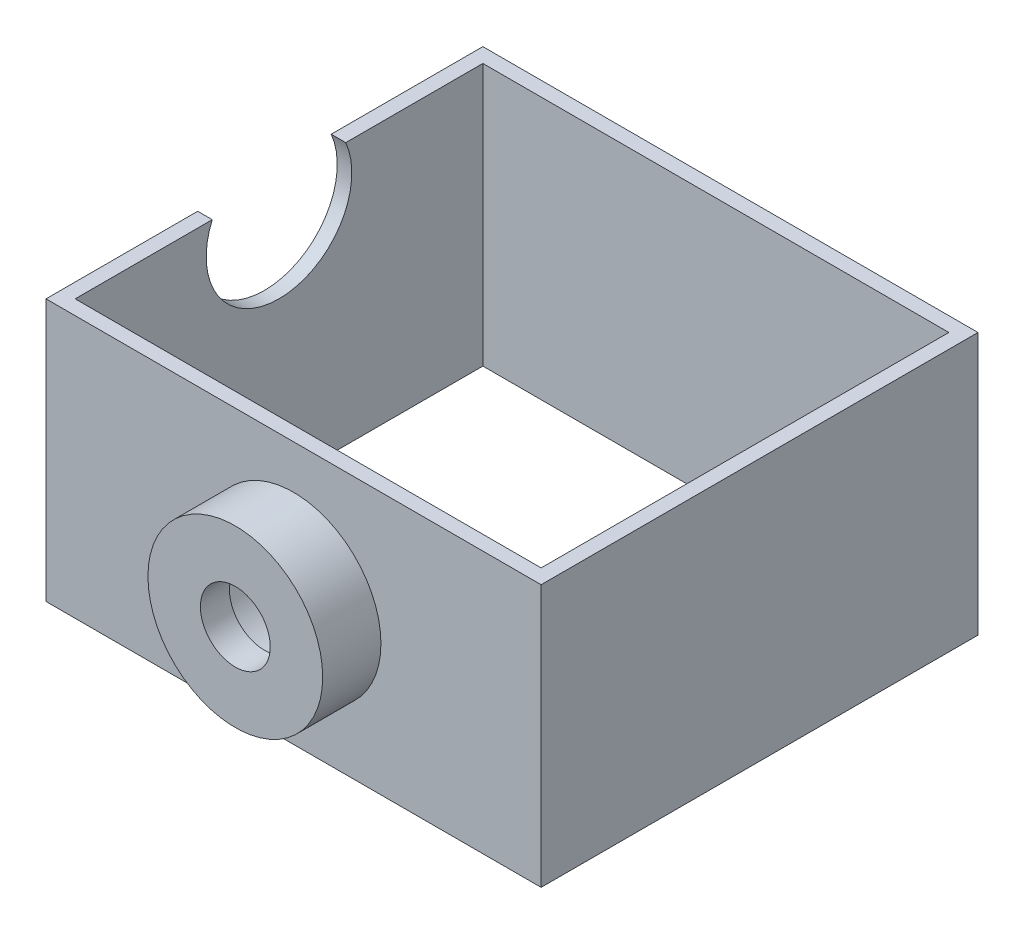
from build123d import *

# Parameters (mm, degrees)
SKETCH2_R           = 15
BOSS_EXTRUDE1_DEPTH = 10
SKETCH4_W           = 85
SKETCH4_H           = 45
BOSS_EXTRUDE2_DEPTH = 75
CUT_EXTRUDE3_REACH  = 47
SKETCH5_W           = 80
SKETCH5_H           = 70
CUT_EXTRUDE1_REACH  = 87
SKETCH3_R           = 6
SKETCH6_R           = 10
CUT_EXTRUDE4_DEPTH  = 7.5
CUT_EXTRUDE5_REACH  = 87
SKETCH7_R           = 12.5


with BuildPart() as part:
    # Sketch2 → Boss-Extrude1 (new body)
    with BuildSketch(Plane.XY):
        Circle(SKETCH2_R)
    extrude(amount=BOSS_EXTRUDE1_DEPTH)

    # Sketch4 → Boss-Extrude2 (add)
    with BuildSketch(Plane(origin=(0, 0, 0), x_dir=(-1, 0, 0), z_dir=(0, 0, -1))):
        Rectangle(SKETCH4_W, SKETCH4_H)
    extrude(amount=BOSS_EXTRUDE2_DEPTH)

    # Sketch5 → Cut-Extrude3 (cut, up to next)
    with BuildSketch(Plane(origin=(0, 22.5, 0), x_dir=(1, 0, 0), z_dir=(0, 1, 0)), mode=Mode.PRIVATE) as cut_extrude3_sk1:
        with Locations((0, 37.5)):
            Rectangle(SKETCH5_W, SKETCH5_H)
    cut_extrude3_tool1 = extrude(cut_extrude3_sk1.sketch, amount=-CUT_EXTRUDE3_REACH, mode=Mode.PRIVATE) & part.part
    add(cut_extrude3_tool1.solids().sort_by_distance((0, 22.5, -37.5))[0], mode=Mode.SUBTRACT)

    # Sketch3 → Cut-Extrude1 (cut, up to next)
    with BuildSketch(Plane.XY.offset(10), mode=Mode.PRIVATE) as cut_extrude1_sk1:
        Circle(SKETCH3_R)
    cut_extrude1_tool1 = extrude(cut_extrude1_sk1.sketch, amount=-CUT_EXTRUDE1_REACH, mode=Mode.PRIVATE) & part.part
    add(cut_extrude1_tool1.solids().sort_by_distance((0, 0, 10))[0], mode=Mode.SUBTRACT)

    # Sketch6 → Cut-Extrude4 (cut)
    with BuildSketch(Plane(origin=(0, 0, -2.5), x_dir=(-1, 0, 0), z_dir=(0, 0, -1))):
        Circle(SKETCH6_R)
    extrude(amount=-CUT_EXTRUDE4_DEPTH, mode=Mode.SUBTRACT)

    # Sketch7 → Cut-Extrude5 (cut, up to next)
    with BuildSketch(Plane.ZY.offset(42.5), mode=Mode.PRIVATE) as cut_extrude5_sk1:
        with Locations((-37.5, 17.5)):
            Circle(SKETCH7_R)
    cut_extrude5_tool1 = extrude(cut_extrude5_sk1.sketch, amount=-CUT_EXTRUDE5_REACH, mode=Mode.PRIVATE) & part.part
    add(cut_extrude5_tool1.solids().sort_by_distance((-42.5, 17.5, -37.5))[0], mode=Mode.SUBTRACT)


solid = part.part
